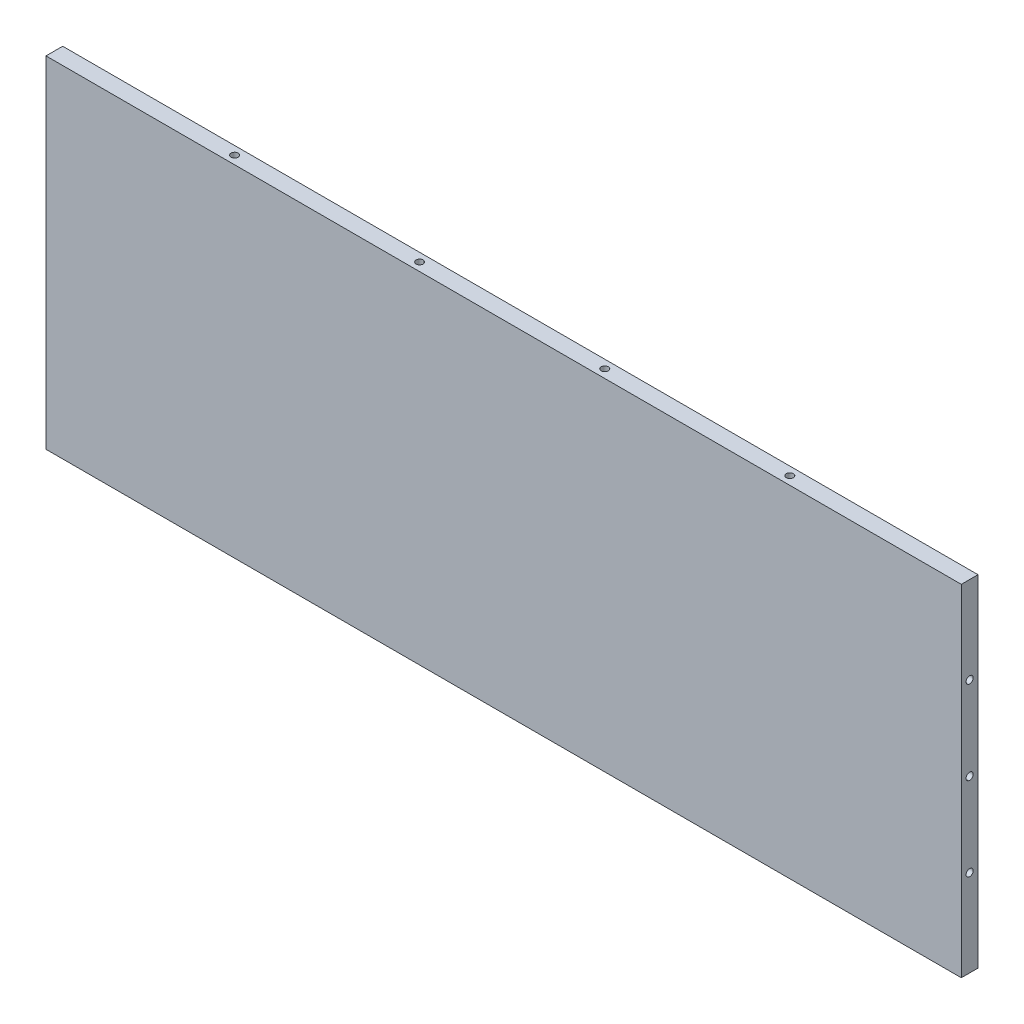
from build123d import *

# Parameters (mm, degrees)
SKETCH1_W                       = 347.98
SKETCH1_H                       = 129.54
BOSS_EXTRUDE1_DEPTH             = 6.35
F_34_0_111_DIAMETER_HOLE4_D     = 2.3749
F_34_0_111_DIAMETER_HOLE4_DEPTH = 17.78
F_34_0_111_DIAMETER_HOLE4_TIP   = 0.713491942
TAP_DRILL_FOR_6_32_TAP1_D       = 2.7051
TAP_DRILL_FOR_6_32_TAP1_DEPTH   = 17.78
TAP_DRILL_FOR_6_32_TAP1_TIP     = 0.81269403
TAP_DRILL_FOR_6_32_TAP2_D       = 2.7051
TAP_DRILL_FOR_6_32_TAP2_DEPTH   = 17.78
TAP_DRILL_FOR_6_32_TAP2_TIP     = 0.81269403
TAP_DRILL_FOR_6_32_TAP3_D       = 2.7051
TAP_DRILL_FOR_6_32_TAP3_DEPTH   = 17.78
TAP_DRILL_FOR_6_32_TAP3_TIP     = 0.81269403


with BuildPart() as part:
    # Sketch1 → Boss-Extrude1 (new body)
    with BuildSketch(Plane.XY):
        with Locations((173.99, 64.77)):
            Rectangle(SKETCH1_W, SKETCH1_H)
    extrude(amount=BOSS_EXTRUDE1_DEPTH)

    # #34 (0.111) Diameter Hole4
    with Locations(Plane(origin=(0, 13.303154199, -243.112488364), x_dir=(0, 0, 1), z_dir=(-1, 0, 0))):
        with Locations((-105.502511636, 81.946845801), (-105.502511636, 56.546845801), (-105.502511636, 31.146845801), (246.287488364, 83.216845801), (246.287488364, 51.466845801), (246.287488364, 19.716845801)):
            Hole(F_34_0_111_DIAMETER_HOLE4_D / 2, depth=F_34_0_111_DIAMETER_HOLE4_DEPTH)
            with Locations((0, 0, -(F_34_0_111_DIAMETER_HOLE4_DEPTH + F_34_0_111_DIAMETER_HOLE4_TIP / 2))):  # 118° drill point
                Cone(0, F_34_0_111_DIAMETER_HOLE4_D / 2, F_34_0_111_DIAMETER_HOLE4_TIP, mode=Mode.SUBTRACT)

    # Tap Drill for #6-32 Tap1
    with Locations(Plane(origin=(-62.772488364, 129.54, -82.602448836), x_dir=(0, 0, -1), z_dir=(0, 1, 0))):
        with Locations((-85.777448836, -342.375688364), (-85.777448836, -272.017688364), (-85.777448836, -201.659688364), (-85.777448836, -131.301688364)):
            Hole(TAP_DRILL_FOR_6_32_TAP1_D / 2, depth=TAP_DRILL_FOR_6_32_TAP1_DEPTH)
            with Locations((0, 0, -(TAP_DRILL_FOR_6_32_TAP1_DEPTH + TAP_DRILL_FOR_6_32_TAP1_TIP / 2))):  # 118° drill point
                Cone(0, TAP_DRILL_FOR_6_32_TAP1_D / 2, TAP_DRILL_FOR_6_32_TAP1_TIP, mode=Mode.SUBTRACT)

    # Tap Drill for #6-32 Tap2
    with Locations(Plane(origin=(-62.772488364, 0, -82.602448836), x_dir=(0, 0, 1), z_dir=(0, -1, 0))):
        with Locations((85.777448836, -131.301688364), (85.777448836, -201.659688364), (85.777448836, -272.017688364), (85.777448836, -342.375688364)):
            Hole(TAP_DRILL_FOR_6_32_TAP2_D / 2, depth=TAP_DRILL_FOR_6_32_TAP2_DEPTH)
            with Locations((0, 0, -(TAP_DRILL_FOR_6_32_TAP2_DEPTH + TAP_DRILL_FOR_6_32_TAP2_TIP / 2))):  # 118° drill point
                Cone(0, TAP_DRILL_FOR_6_32_TAP2_D / 2, TAP_DRILL_FOR_6_32_TAP2_TIP, mode=Mode.SUBTRACT)

    # Tap Drill for #6-32 Tap3
    with Locations(Plane(origin=(347.98, 0, 0), x_dir=(0, 0, -1), z_dir=(1, 0, 0))):
        with Locations((-3.175, 64.77), (-3.175, 96.52), (-3.175, 33.02)):
            Hole(TAP_DRILL_FOR_6_32_TAP3_D / 2, depth=TAP_DRILL_FOR_6_32_TAP3_DEPTH)
            with Locations((0, 0, -(TAP_DRILL_FOR_6_32_TAP3_DEPTH + TAP_DRILL_FOR_6_32_TAP3_TIP / 2))):  # 118° drill point
                Cone(0, TAP_DRILL_FOR_6_32_TAP3_D / 2, TAP_DRILL_FOR_6_32_TAP3_TIP, mode=Mode.SUBTRACT)


solid = part.part
